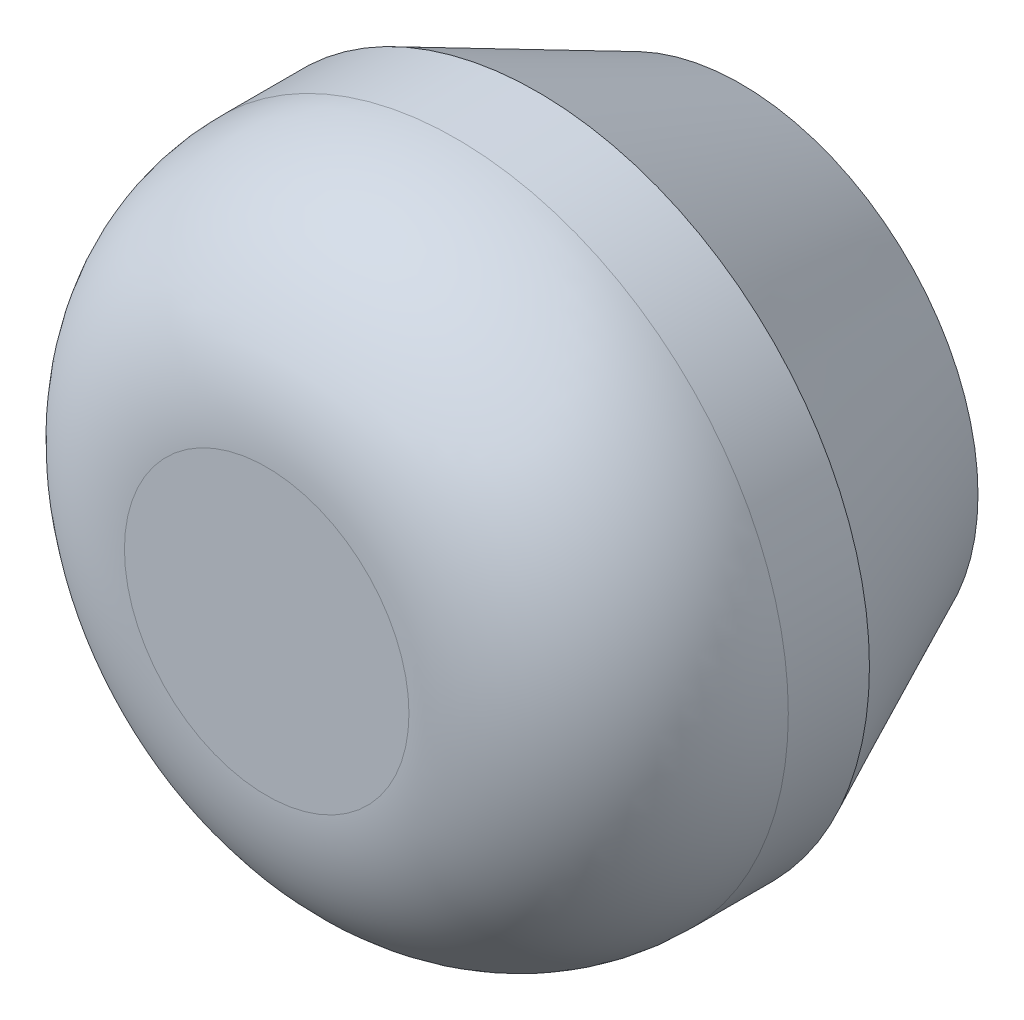
from build123d import *

# Parameters (mm, degrees)
SKETCH_1_R          = 3.5
EXTRUDE_1_DEPTH     = 5
FILLET_1_R          = 2
SKETCH_2_W          = 2.6
SKETCH_2_H          = 2.6
CUT_EXTRUDE_1_DEPTH = 4
CHAMFER_1_SIZE      = 1
CHAMFER_1_SIZE2     = 2.144506921


with BuildPart() as part:
    # Эскиз1 → Бобышка-Вытянуть1 (new body)
    with BuildSketch(Plane.XY):
        Circle(SKETCH_1_R)
    extrude(amount=EXTRUDE_1_DEPTH)

    # Скругление1
    fillet_1_edges = [part.edges().sort_by_distance(p)[0] for p in [
        (-3.5, 0, 5),
    ]]
    fillet(fillet_1_edges, radius=FILLET_1_R)

    # Эскиз2 → Вырез-Вытянуть1 (cut)
    with BuildSketch(Plane(origin=(0, 0, 0), x_dir=(-1, 0, 0), z_dir=(0, 0, -1))):
        Rectangle(SKETCH_2_W, SKETCH_2_H)
    extrude(amount=-CUT_EXTRUDE_1_DEPTH, mode=Mode.SUBTRACT)

    # Фаска1
    chamfer_1_edges = [part.edges().sort_by_distance(p)[0] for p in [
        (-3.5, 0, 0),
    ]]
    chamfer_1_side = [part.faces().sort_by_distance(p)[0] for p in [
        (-3.401005051, 0, 0),
    ]]
    chamfer(chamfer_1_edges, length=CHAMFER_1_SIZE, length2=CHAMFER_1_SIZE2, reference=chamfer_1_side[0])


solid = part.part
